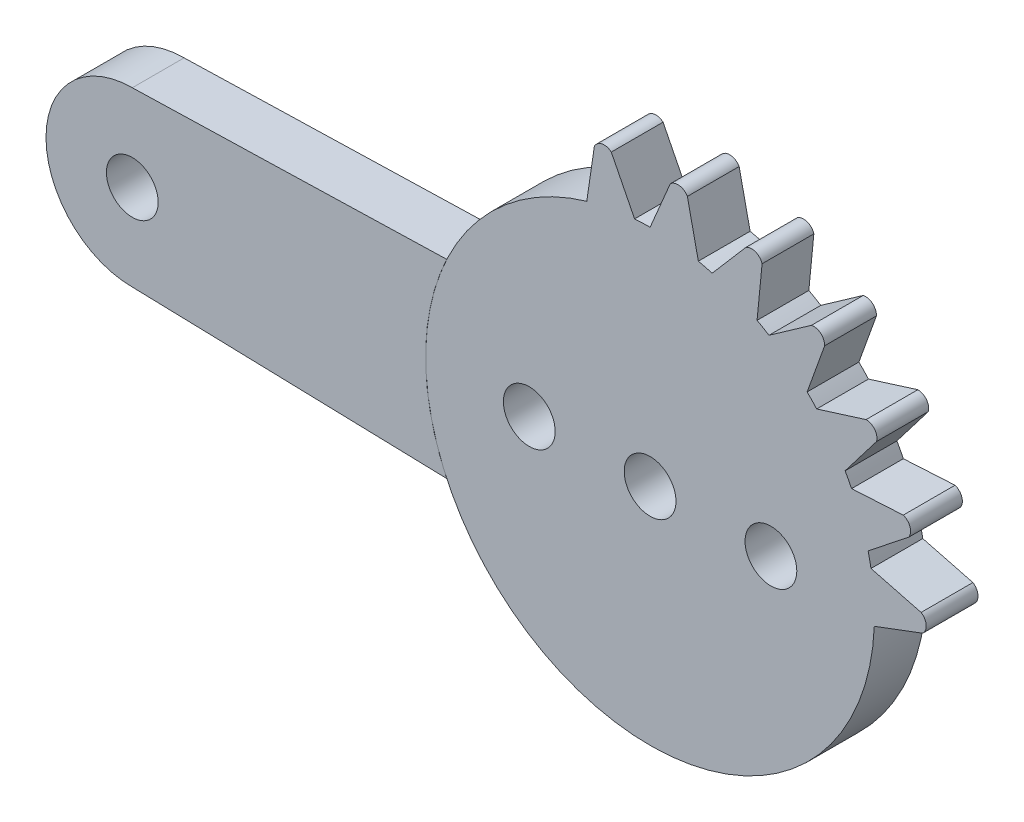
from build123d import *

# Parameters (mm, degrees)
SCHIZZO1_R                   = 13
SCHIZZO1_R_2                 = 1.5
ESTRUSIONE_ESTRUSIONE1_DEPTH = 3
SCHIZZO2_R                   = 1.5
ESTRUSIONE_ESTRUSIONE2_DEPTH = 3
ESTRUSIONE_ESTRUSIONE3_DEPTH = 3


with BuildPart() as part:
    # Schizzo1 → Estrusione-Estrusione1 (new body)
    with BuildSketch(Plane.XY):
        Circle(SCHIZZO1_R)
        with Locations((-7, 0)):
            Circle(SCHIZZO1_R_2, mode=Mode.SUBTRACT)
        with Locations((7, 0)):
            Circle(SCHIZZO1_R_2, mode=Mode.SUBTRACT)
        Circle(SCHIZZO1_R_2, mode=Mode.SUBTRACT)
    extrude(amount=ESTRUSIONE_ESTRUSIONE1_DEPTH)

    # Schizzo3 → Estrusione-Estrusione3 (add)
    with BuildSketch(Plane.XY):
        with BuildLine():
            ThreePointArc((2.160070392, 15.627933395), (1.697201955, 15.940072625), (1.16759145, 15.763463444))
            Line((1.16759145, 15.763463444), (0, 13))
            ThreePointArc((0, 13), (1.40584798, 12.923760732), (2.795206602, 12.695937147))
            Line((2.795206602, 12.695937147), (2.160070392, 15.627933395))
        make_face()
        with BuildLine():
            ThreePointArc((-3.598471304, 12.492037635), (-2.266143189, 12.800960708), (-0.908732869, 12.968199743))
            Line((-0.908732869, 12.968199743), (-0.898912385, 12.969938255))
            Line((-0.898912385, 12.969938255), (-2.248522058, 15.649220571))
            ThreePointArc((-2.248522058, 15.649220571), (-2.78874852, 15.790051886), (-3.229728761, 15.44768583))
            Line((-3.229728761, 15.44768583), (-3.667559269, 12.479807051))
            Line((-3.667559269, 12.479807051), (-3.598471304, 12.492037635))
        make_face()
        with BuildLine():
            Line((5.551256778, 14.767591357), (3.595206602, 12.492977607))
            ThreePointArc((3.595206602, 12.492977607), (4.925139788, 12.030918422), (6.197305427, 11.427747173))
            Line((6.197305427, 11.427747173), (6.488312128, 14.413599664))
            ThreePointArc((6.488312128, 14.413599664), (6.106946442, 14.821322981), (5.551256778, 14.767591357))
        make_face()
        with BuildLine():
            ThreePointArc((12.798690895, 2.278927679), (12.970080361, 0.881484793), (12.989342221, -0.526297133))
            Line((12.989342221, -0.526297133), (15.79780933, 0.528459946))
            ThreePointArc((15.79780933, 0.528459946), (15.995714682, 1.050486345), (15.702570302, 1.525612078))
            Line((15.702570302, 1.525612078), (12.798690895, 2.278927679))
        make_face()
        with BuildLine():
            Line((9.342997115, 12.74984135), (6.888483888, 11.024916768))
            ThreePointArc((6.888483888, 11.024916768), (8.040344195, 10.215325018), (9.097898355, 9.285916515))
            Line((9.097898355, 9.285916515), (10.112874129, 12.109004218))
            ThreePointArc((10.112874129, 12.109004218), (9.885726441, 12.618986587), (9.342997115, 12.74984135))
        make_face()
        with BuildLine():
            Line((12.514244156, 9.60686731), (9.651842013, 8.708728137))
            ThreePointArc((9.651842013, 8.708728137), (10.53701882, 7.613884317), (11.298605688, 6.429736349))
            Line((11.298605688, 6.429736349), (13.122911734, 8.811313022))
            ThreePointArc((13.122911734, 8.811313022), (13.014464163, 9.358960001), (12.514244156, 9.60686731))
        make_face()
        with BuildLine():
            ThreePointArc((11.672700614, 5.722592102), (12.223098799, 4.426720655), (12.630130813, 3.078927679))
            Line((12.630130813, 3.078927679), (14.983183808, 4.939879478))
            ThreePointArc((14.983183808, 4.939879478), (15.059699232, 5.49289257), (14.667987618, 5.890686613))
            Line((14.667987618, 5.890686613), (11.672700614, 5.722592102))
        make_face()
    extrude(amount=ESTRUSIONE_ESTRUSIONE3_DEPTH)


with BuildPart() as body_2:
    # Schizzo2 → Estrusione-Estrusione2 (new body)
    with BuildSketch(Plane.XY):
        with BuildLine():
            Line((-11.784238345, 5.499862263), (-30, 5))
            ThreePointArc((-30, 5), (-35, 0), (-30, -5))
            Line((-30, -5), (-11.784238345, -5.499862263))
            ThreePointArc((-11.784238345, -5.499862263), (-13.004489928, 0), (-11.784238345, 5.499862263))
        make_face()
        with Locations((-30, 0)):
            Circle(SCHIZZO2_R, mode=Mode.SUBTRACT)
    extrude(amount=ESTRUSIONE_ESTRUSIONE2_DEPTH)


solid = Compound([part.part, body_2.part])
